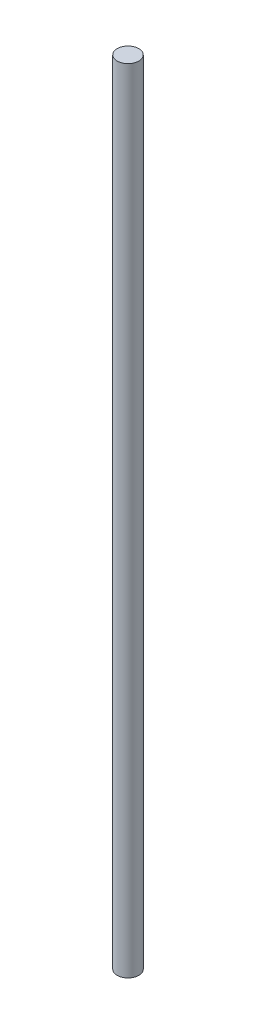
from build123d import *

# Parameters (mm, degrees)
SKETCH1_R           = 4.7625
BOSS_EXTRUDE1_DEPTH = 349.25


with BuildPart() as part:
    # Sketch1 → Boss-Extrude1 (new body)
    with BuildSketch(Plane(origin=(0, 0, 0), x_dir=(1, 0, 0), z_dir=(0, 1, 0))):
        Circle(SKETCH1_R)
    extrude(amount=BOSS_EXTRUDE1_DEPTH)


solid = part.part
